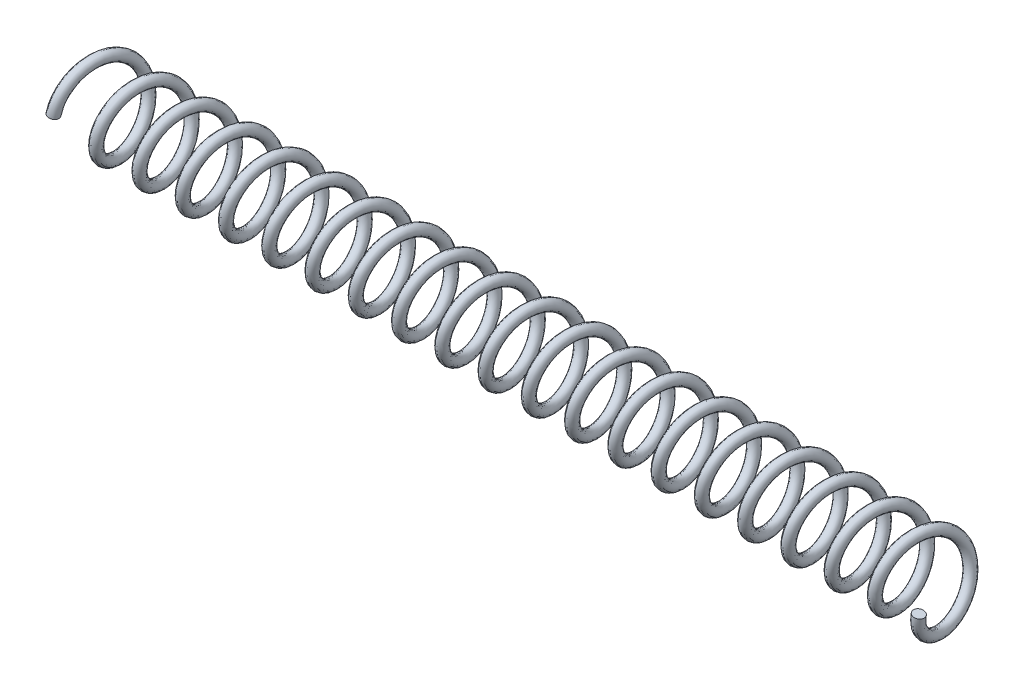
from build123d import *

# Parameters (mm, degrees)
SWEEP1_PITCH     = 1
SWEEP1_HEIGHT    = 20
SWEEP1_RADIUS    = 0.839130528
SWEEP1_PROFILE_R = 0.125


with BuildPart() as part:
    # Sweep1: sweep along a helix
    with BuildLine() as sweep1_path:
        Helix(SWEEP1_PITCH, SWEEP1_HEIGHT, SWEEP1_RADIUS, center=(0, 34, 0), direction=(1, 0, 0), lefthand=True)
    # Sweep1 profile (on start of the path) → Sweep1 (sweep)
    with BuildSketch(Plane(origin=(0, 34, 0.839130528), x_dir=(0.982484488, -0.186344386, 0), z_dir=(0.186344386, 0.982484488, 0))):
        Circle(SWEEP1_PROFILE_R)
    sweep(path=sweep1_path.line, is_frenet=True)


solid = part.part
